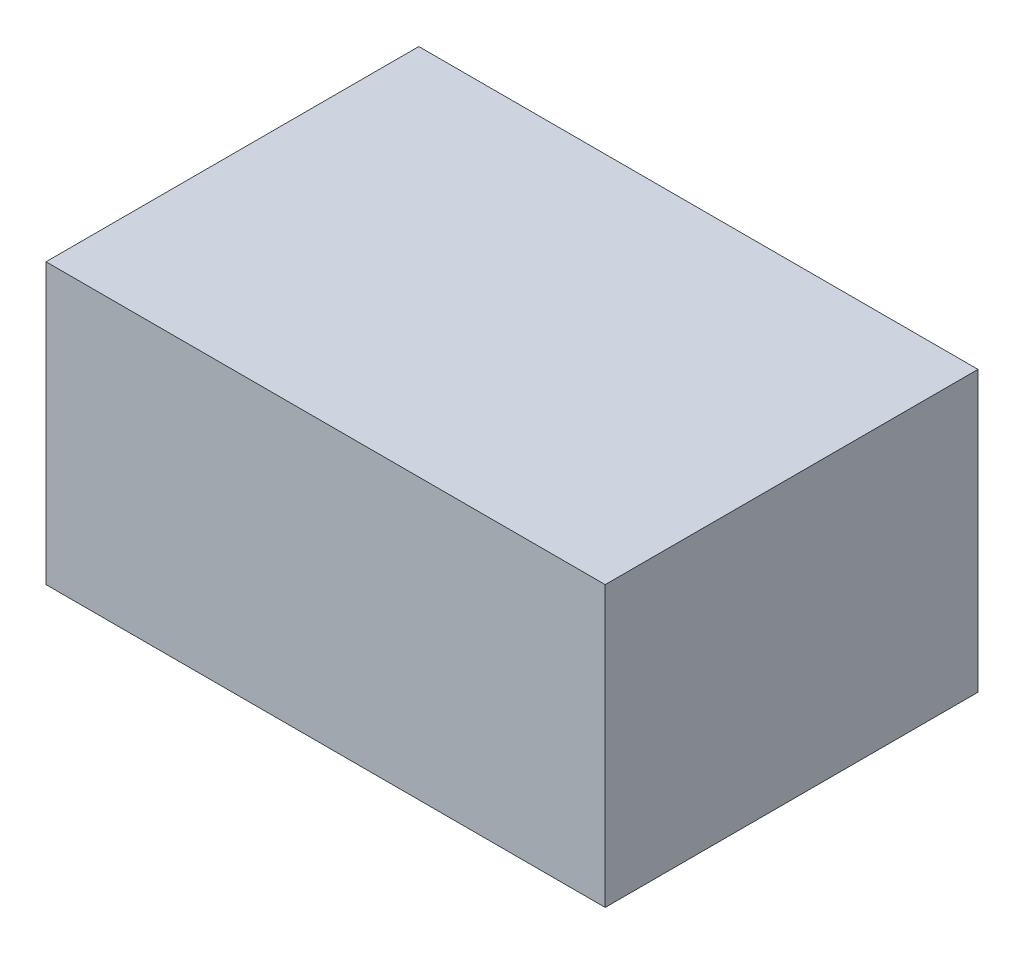
from build123d import *

# Parameters (mm, degrees)
SKETCH1_W           = 600
SKETCH1_H           = 300
BOSS_EXTRUDE1_DEPTH = 400


with BuildPart() as part:
    # Sketch1 → Boss-Extrude1 (new body)
    with BuildSketch(Plane.XY):
        with Locations((300, 150)):
            Rectangle(SKETCH1_W, SKETCH1_H)
    extrude(amount=BOSS_EXTRUDE1_DEPTH)


solid = part.part
